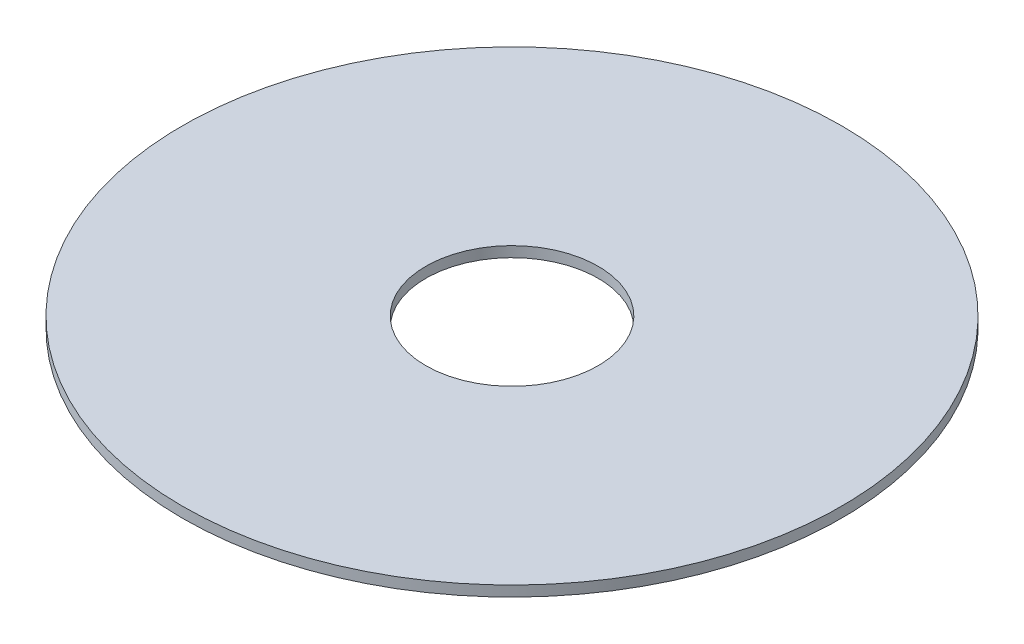
from build123d import *

# Parameters (mm, degrees)
SKETCH1_R           = 53.5344
SKETCH1_R_2         = 14
BOSS_EXTRUDE1_DEPTH = 1.7
SCALE2_SCALE        = 0.75


with BuildPart() as part:
    # Sketch1 → Boss-Extrude1 (new body)
    with BuildSketch(Plane(origin=(0, 0, 0), x_dir=(1, 0, 0), z_dir=(0, 1, 0))):
        Circle(SKETCH1_R)
        Circle(SKETCH1_R_2, mode=Mode.SUBTRACT)
    extrude(amount=BOSS_EXTRUDE1_DEPTH)


with BuildPart() as part_1:
    # Scale2: scaled about (0, 0.85, 0)
    add(part.part.scale(SCALE2_SCALE).moved(Location((0, 0.2125, 0))))


solid = part_1.part
